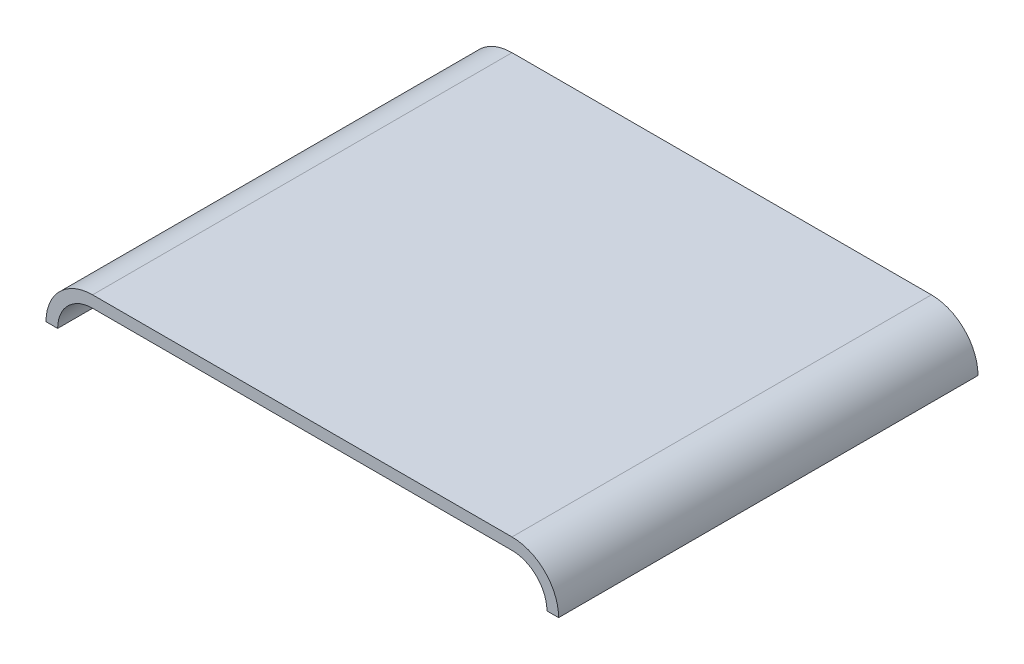
from build123d import *

# Parameters (mm, degrees)
EXTRUDE_THIN1_DEPTH = 457.2


with BuildPart() as part:
    # Sketch1 → Extrude-Thin1 (new body)
    with BuildSketch(Plane.XY):
        with BuildLine():
            Line((0, 0), (228.6, 0))
            ThreePointArc((228.6, 0), (264.521024484, -14.878975516), (279.4, -50.8))
            Line((279.4, -50.8), (266.7, -50.8))
            ThreePointArc((266.7, -50.8), (255.540768363, -23.859231637), (228.6, -12.7))
            Line((228.6, -12.7), (0, -12.7))
            Line((0, -12.7), (0, 0))
        make_face()
    extrude_thin1 = extrude(amount=EXTRUDE_THIN1_DEPTH)

    # Mirror1: Extrude-Thin1 across plane
    add(extrude_thin1.mirror(Plane(origin=(0, -12.7, 457.2), x_dir=(0, 0, 1), z_dir=(-1, 0, 0))))


solid = part.part
